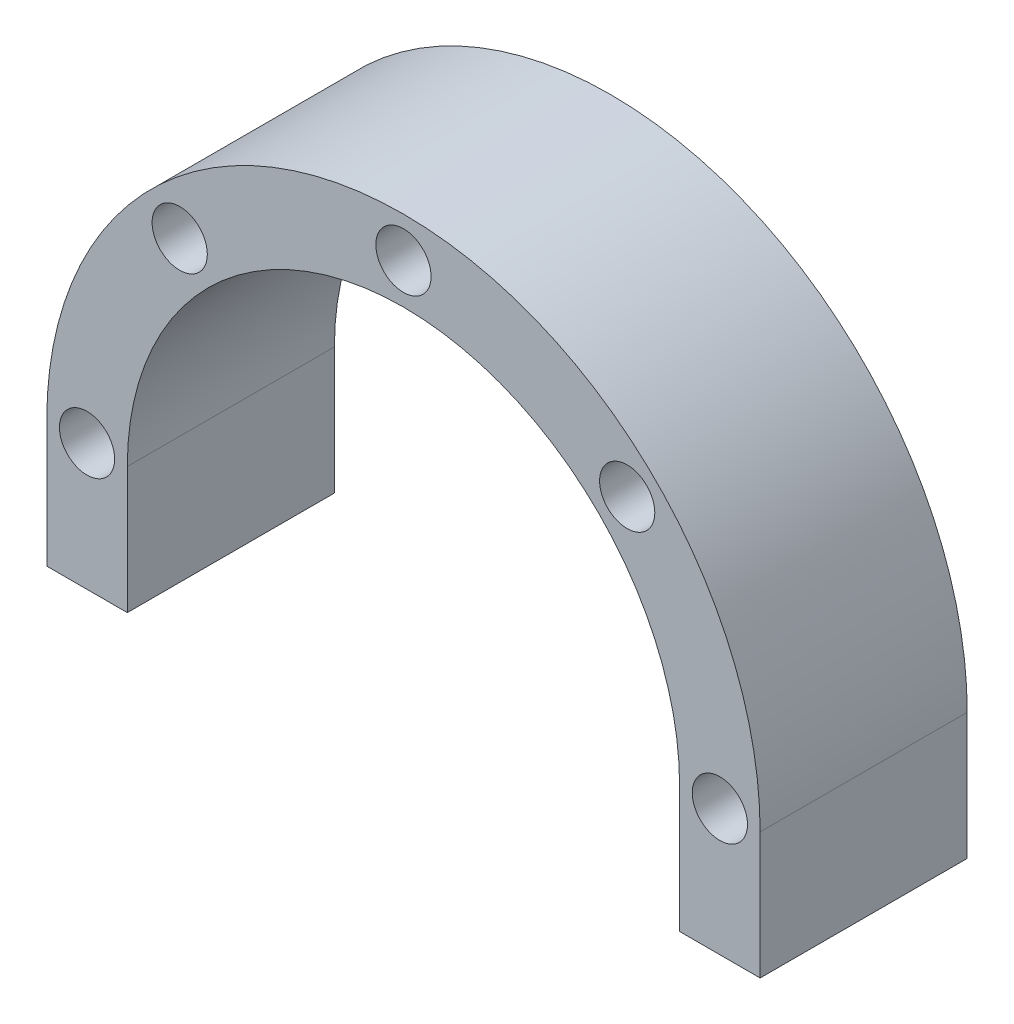
from build123d import *

# Parameters (mm, degrees)
EXTRUDE_1_DEPTH          = 18
CUT_EXTRUDE_1_DEPTH      = 19
HOLE_WIZARD_M4_2_D       = 4.8
PATTERN_CIRCULAR_1_COUNT = 8


with BuildPart() as part:
    # ｽｹｯﾁ1 → ﾎﾞｽ - 押し出し1 (new body)
    with BuildSketch(Plane.XY):
        with BuildLine():
            ThreePointArc((-31, 0), (0, 31), (31, 0))
            Line((31, 0), (31, -11))
            Line((31, -11), (-31, -11))
            Line((-31, -11), (-31, 0))
        make_face()
    extrude(amount=EXTRUDE_1_DEPTH)

    # ｽｹｯﾁ2 → ｶｯﾄ - 押し出し1 (cut, through all)
    with BuildSketch(Plane.XY.offset(18)):
        with BuildLine():
            Line((-24, 0), (-24, -11))
            Line((-24, -11), (24, -11))
            Line((24, -11), (24, 0))
            ThreePointArc((24, 0), (0, 24), (-24, 0))
        make_face()
    extrude(amount=-CUT_EXTRUDE_1_DEPTH, mode=Mode.SUBTRACT)

    # M4 すきま穴2 (through all)
    with Locations(Plane.XY.offset(18)):
        with Locations((0, 27.5)):
            hole_wizard_m4_2 = Hole(HOLE_WIZARD_M4_2_D / 2)

    # 円形ﾊﾟﾀｰﾝ1: M4 すきま穴2 ×8 about axis, 3 skipped
    pattern_circular_1_axis = Axis((0, 0, 0), (0, 0, -1))
    add([hole_wizard_m4_2.rotate(pattern_circular_1_axis, i * 360 / PATTERN_CIRCULAR_1_COUNT) for i in range(1, PATTERN_CIRCULAR_1_COUNT) if i not in (3, 4, 5)], mode=Mode.SUBTRACT)


solid = part.part
